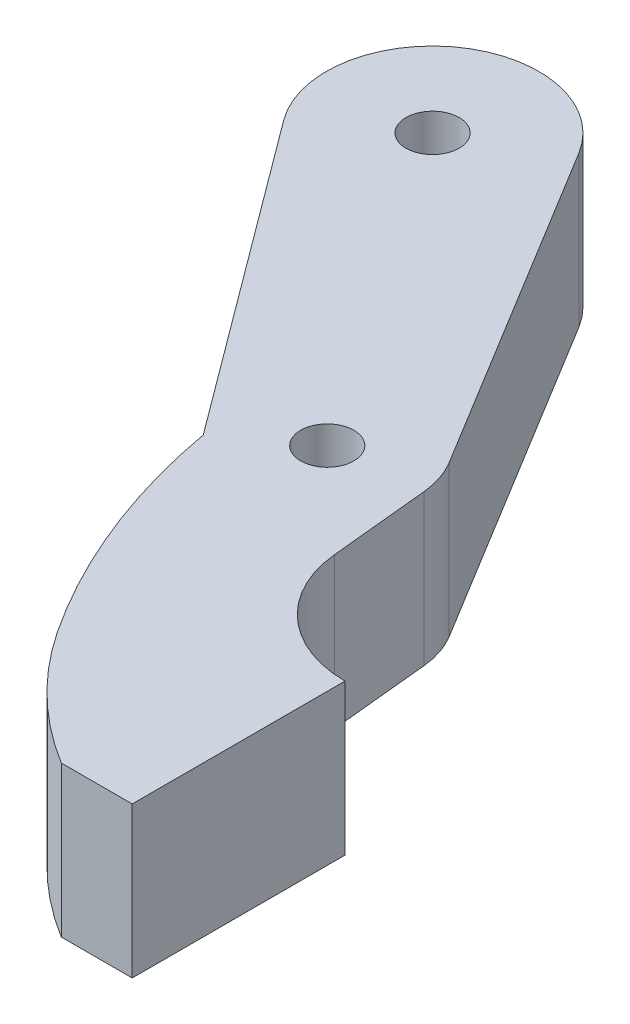
from build123d import *

# Parameters (mm, degrees)
CROQUIS1_R              = 1.5
SALIENTE_EXTRUIR1_DEPTH = 8.5


with BuildPart() as part:
    # Croquis1 → Saliente-Extruir1 (new body)
    with BuildSketch(Plane(origin=(0, 0, 0), x_dir=(1, 0, 0), z_dir=(0, 1, 0))):
        with BuildLine():
            Line((-29.118820837, 29.661035883), (-16.013814133, 12.018507739))
            ThreePointArc((-16.013814133, 12.018507739), (-13.96004638, 4.867227057), (-10.5, -1.719642946))
            ThreePointArc((-10.5, -1.719642946), (-7.591888883, -5.213667237), (-4, -8))
            Line((-4, -8), (0, -8))
            Line((0, -8), (0, 4))
            ThreePointArc((0, 4), (-4.364647968, 5.683377936), (-6.468572218, 9.861585197))
            Line((-6.468572218, 9.861585197), (-7.024175217, 15.49108831))
            ThreePointArc((-7.024175217, 15.49108831), (-7.25881516, 16.587818098), (-7.732007274, 17.604657001))
            Line((-7.732007274, 17.604657001), (-19.180652605, 36.364414997))
            ThreePointArc((-19.180652605, 36.364414997), (-27.657401297, 38.213052032), (-29.118820837, 29.661035883))
        make_face()
        with Locations((-24.302243876, 33.238826596)):
            Circle(CROQUIS1_R, mode=Mode.SUBTRACT)
        with Locations((-12, 15)):
            Circle(CROQUIS1_R, mode=Mode.SUBTRACT)
    extrude(amount=SALIENTE_EXTRUIR1_DEPTH)


solid = part.part
